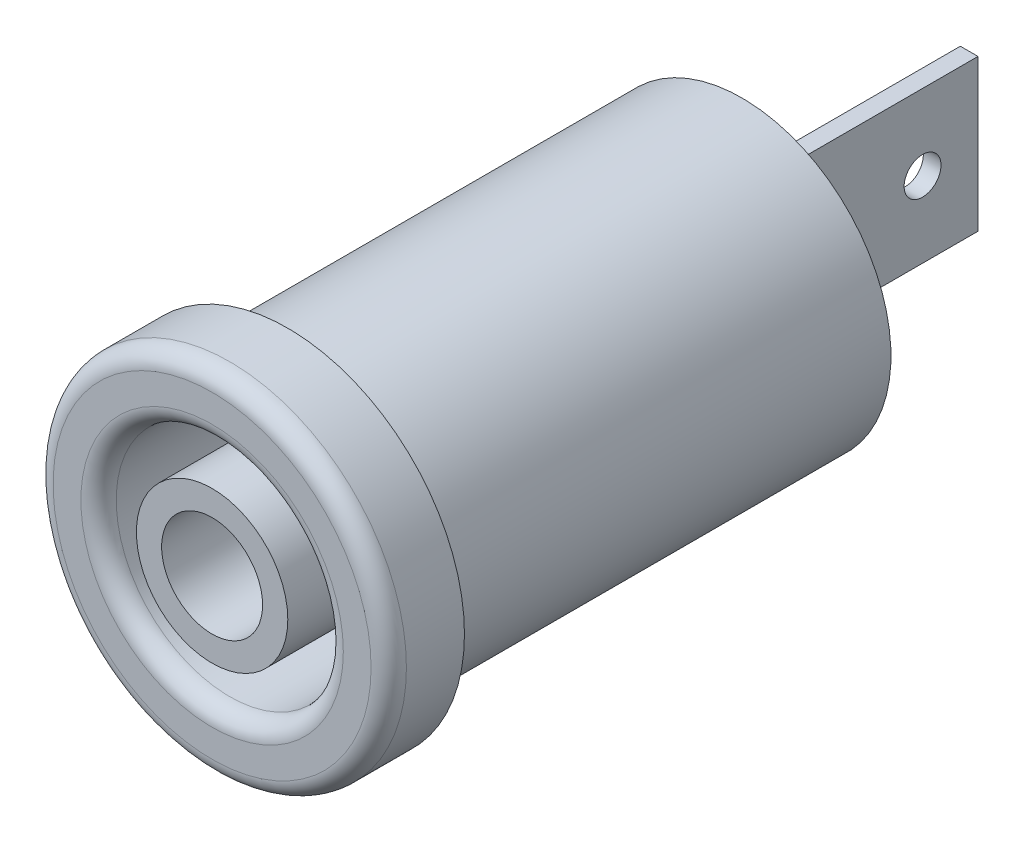
from build123d import *

# Parameters (mm, degrees)
SKETCH1_R           = 7
BOSS_EXTRUDE1_DEPTH = 3
SKETCH2_R           = 5.9
BOSS_EXTRUDE2_DEPTH = 18
SKETCH3_W           = 0.7
SKETCH3_H           = 6
BOSS_EXTRUDE3_DEPTH = 9
SKETCH4_R           = 0.730989372
CUT_EXTRUDE1_DEPTH  = 0.7
SKETCH8_R           = 4.5
CUT_EXTRUDE2_DEPTH  = 10
SKETCH9_R           = 3
BOSS_EXTRUDE4_DEPTH = 10
SKETCH10_R          = 2
CUT_EXTRUDE3_DEPTH  = 10
FILLET3_R           = 0.7


with BuildPart() as part:
    # Sketch1 → Boss-Extrude1 (new body)
    with BuildSketch(Plane.XY):
        Circle(SKETCH1_R)
    extrude(amount=BOSS_EXTRUDE1_DEPTH)

    # Sketch2 → Boss-Extrude2 (add)
    with BuildSketch(Plane(origin=(0, 0, 0), x_dir=(-1, 0, 0), z_dir=(0, 0, -1))):
        Circle(SKETCH2_R)
    extrude(amount=BOSS_EXTRUDE2_DEPTH)

    # Sketch3 → Boss-Extrude3 (add)
    with BuildSketch(Plane(origin=(0, 0, -18), x_dir=(-1, 0, 0), z_dir=(0, 0, -1))):
        Rectangle(SKETCH3_W, SKETCH3_H)
    extrude(amount=BOSS_EXTRUDE3_DEPTH)

    # Sketch4 → Cut-Extrude1 (cut)
    with BuildSketch(Plane(origin=(0.35, 0, 0), x_dir=(0, 0, -1), z_dir=(1, 0, 0))):
        with Locations((24.802762054, 0)):
            Circle(SKETCH4_R)
    extrude(amount=-CUT_EXTRUDE1_DEPTH, mode=Mode.SUBTRACT)

    # Sketch8 → Cut-Extrude2 (cut)
    with BuildSketch(Plane.XY.offset(3)):
        Circle(SKETCH8_R)
    extrude(amount=-CUT_EXTRUDE2_DEPTH, mode=Mode.SUBTRACT)

    # Sketch9 → Boss-Extrude4 (add)
    with BuildSketch(Plane.XY.offset(-7)):
        Circle(SKETCH9_R)
    extrude(amount=BOSS_EXTRUDE4_DEPTH)

    # Sketch10 → Cut-Extrude3 (cut)
    with BuildSketch(Plane.XY.offset(3)):
        Circle(SKETCH10_R)
    extrude(amount=-CUT_EXTRUDE3_DEPTH, mode=Mode.SUBTRACT)

    # Fillet3
    fillet3_edges = [part.edges().sort_by_distance(p)[0] for p in [
        (-4.5, 0, 3),
        (-7, 0, 3),
    ]]
    fillet(fillet3_edges, radius=FILLET3_R)


solid = part.part
